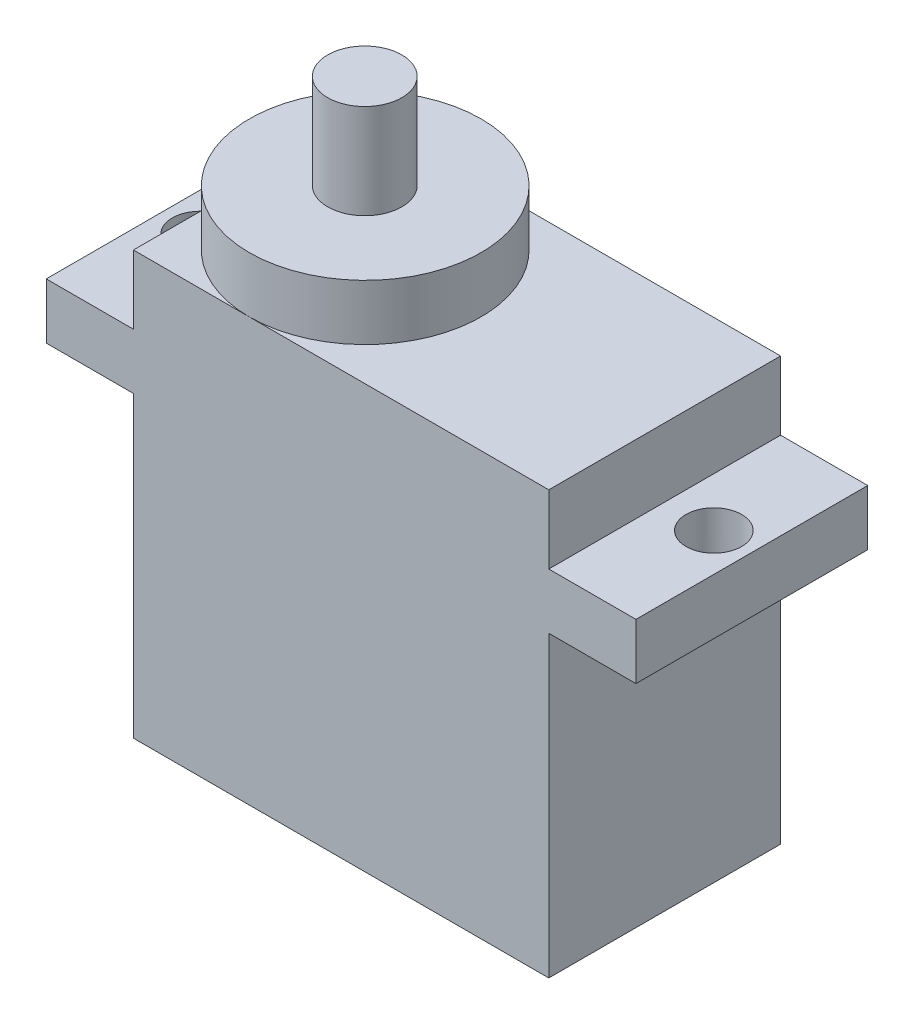
from build123d import *

# Parameters (mm, degrees)
SKETCH_1_W          = 22.4
SKETCH_1_H          = 12.5
EXTRUDE_1_DEPTH     = 22.8
SKETCH_2_W          = 12.5
SKETCH_2_H          = 3
EXTRUDE_2_DEPTH     = 4.7
SKETCH_3_W          = 12.5
SKETCH_3_H          = 3
EXTRUDE_3_DEPTH     = 4.7
SKETCH_4_R          = 1.5
CUT_EXTRUDE_1_DEPTH = 4.7
SKETCH_5_R          = 6.25
EXTRUDE_5_DEPTH     = 3
SKETCH_6_R          = 2
EXTRUDE_6_DEPTH     = 5.1


with BuildPart() as part:
    # 草图1 → 凸台-拉伸1 (new body)
    with BuildSketch(Plane(origin=(0, 0, 0), x_dir=(1, 0, 0), z_dir=(0, 1, 0))):
        with Locations((11.2, -6.25)):
            Rectangle(SKETCH_1_W, SKETCH_1_H)
    extrude(amount=EXTRUDE_1_DEPTH)

    # 草图2 → 凸台-拉伸2 (add)
    with BuildSketch(Plane(origin=(22.4, 0, 0), x_dir=(0, 0, -1), z_dir=(1, 0, 0))):
        with Locations((-6.25, 17.6)):
            Rectangle(SKETCH_2_W, SKETCH_2_H)
    extrude(amount=EXTRUDE_2_DEPTH)

    # 草图3 → 凸台-拉伸3 (add)
    with BuildSketch(Plane.ZY):
        with Locations((6.25, 17.6)):
            Rectangle(SKETCH_3_W, SKETCH_3_H)
    extrude(amount=EXTRUDE_3_DEPTH)

    # 草图4 → 切除-拉伸1 (cut)
    with BuildSketch(Plane(origin=(0, 19.1, 0), x_dir=(1, 0, 0), z_dir=(0, 1, 0))):
        with Locations((-2.65, -6.25)):
            Circle(SKETCH_4_R)
        with Locations((25.05, -6.25)):
            Circle(SKETCH_4_R)
    extrude(amount=-CUT_EXTRUDE_1_DEPTH, mode=Mode.SUBTRACT)

    # 草图5 → 凸台-拉伸5 (add)
    with BuildSketch(Plane(origin=(0, 22.8, 0), x_dir=(1, 0, 0), z_dir=(0, 1, 0))):
        with Locations((6.25, -6.25)):
            Circle(SKETCH_5_R)
    extrude(amount=EXTRUDE_5_DEPTH)

    # 草图6 → 凸台-拉伸6 (add)
    with BuildSketch(Plane(origin=(0, 25.8, 0), x_dir=(1, 0, 0), z_dir=(0, 1, 0))):
        with Locations((6.225516092, -6.25)):
            Circle(SKETCH_6_R)
    extrude(amount=EXTRUDE_6_DEPTH)


solid = part.part
